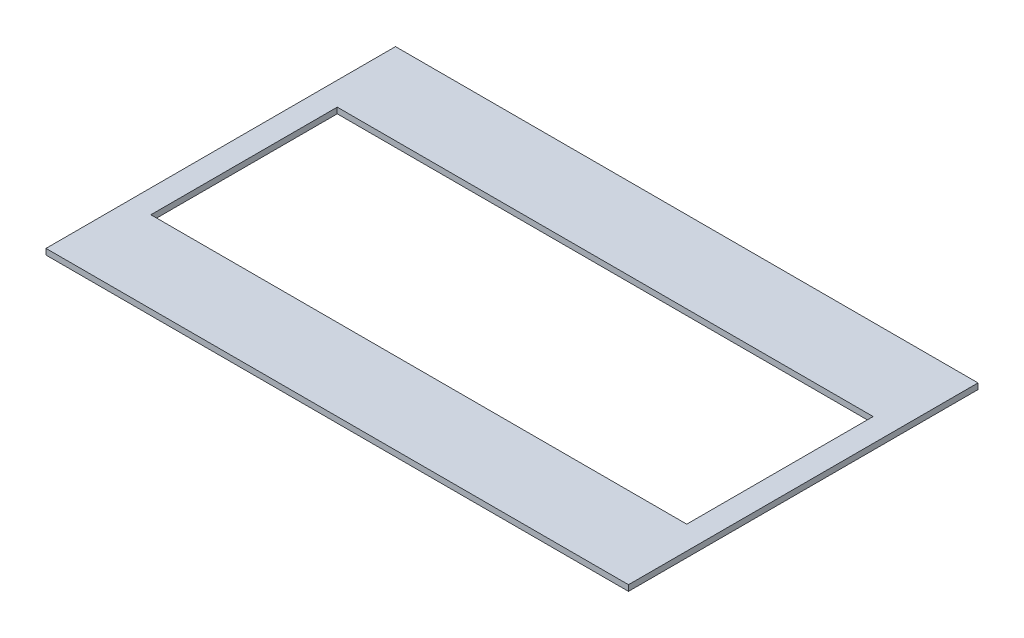
from build123d import *

# Parameters (mm, degrees)
SKETCH1_W           = 500
SKETCH1_H           = 300
BOSS_EXTRUDE1_DEPTH = 5
SKETCH2_W           = 460
SKETCH2_H           = 160
CUT_EXTRUDE1_DEPTH  = 10


with BuildPart() as part:
    # Sketch1 → Boss-Extrude1 (new body)
    with BuildSketch(Plane(origin=(0, 0, 0), x_dir=(1, 0, 0), z_dir=(0, 1, 0))):
        Rectangle(SKETCH1_W, SKETCH1_H)
    extrude(amount=BOSS_EXTRUDE1_DEPTH)

    # Sketch2 → Cut-Extrude1 (cut)
    with BuildSketch(Plane(origin=(0, 5, 0), x_dir=(1, 0, 0), z_dir=(0, 1, 0))):
        Rectangle(SKETCH2_W, SKETCH2_H)
    extrude(amount=-CUT_EXTRUDE1_DEPTH, mode=Mode.SUBTRACT)


solid = part.part
